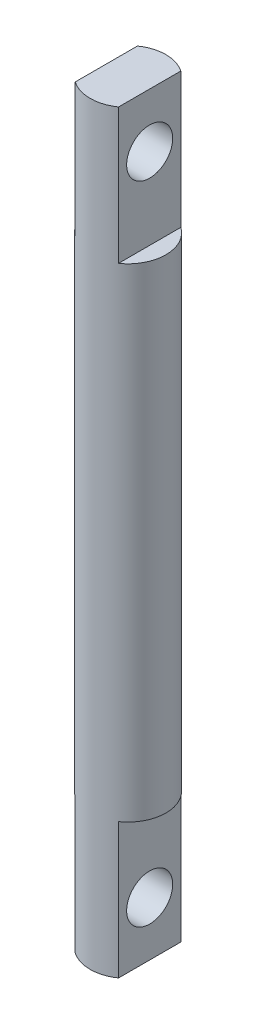
from build123d import *

# Parameters (mm, degrees)
SKETCH1_R                        = 7
BOSS_EXTRUDE1_DEPTH              = 139.254
SKETCH3_W                        = 3.842840079
SKETCH3_H                        = 19.362001934
SKETCH3_W_2                      = 3.621137766
CUT_EXTRUDE1_DEPTH               = 25
SKETCH4_W                        = 4.298001377
SKETCH4_H                        = 18.624672635
SKETCH4_W_2                      = 5.056472209
SKETCH4_H_2                      = 19.003908051
CUT_EXTRUDE2_DEPTH               = 25
TAP_DRILL_FOR_M10X1_5_TAP1_D     = 8.5
TAP_DRILL_FOR_M10X1_5_TAP1_DEPTH = 20
TAP_DRILL_FOR_M10X1_5_TAP1_TIP   = 2.553657631


with BuildPart() as part:
    # Sketch1 → Boss-Extrude1 (new body)
    with BuildSketch(Plane(origin=(0, 0, 0), x_dir=(1, 0, 0), z_dir=(0, 1, 0))):
        Circle(SKETCH1_R)
    extrude(amount=BOSS_EXTRUDE1_DEPTH)

    # Sketch3 → Cut-Extrude1 (cut)
    with BuildSketch(Plane.XZ):
        with Locations((5.92142004, -0.588495195)):
            Rectangle(SKETCH3_W, SKETCH3_H)
        with Locations((-5.810568883, -0.588495195)):
            Rectangle(SKETCH3_W_2, SKETCH3_H)
    extrude(amount=-CUT_EXTRUDE1_DEPTH, mode=Mode.SUBTRACT)

    # Sketch4 → Cut-Extrude2 (cut)
    with BuildSketch(Plane(origin=(0, 139.254, 0), x_dir=(1, 0, 0), z_dir=(0, 1, 0))):
        with Locations((-6.149000689, -0.400304049)):
            Rectangle(SKETCH4_W, SKETCH4_H)
        with Locations((6.528236105, -0.589921757)):
            Rectangle(SKETCH4_W_2, SKETCH4_H_2)
    extrude(amount=-CUT_EXTRUDE2_DEPTH, mode=Mode.SUBTRACT)

    # Tap Drill for M10x1.5 Tap1
    with Locations(Plane(origin=(4, 0, 0), x_dir=(0, 0, -1), z_dir=(1, 0, 0))):
        with Locations((0, 129.254), (0, 10)):
            Hole(TAP_DRILL_FOR_M10X1_5_TAP1_D / 2, depth=TAP_DRILL_FOR_M10X1_5_TAP1_DEPTH)
            with Locations((0, 0, -(TAP_DRILL_FOR_M10X1_5_TAP1_DEPTH + TAP_DRILL_FOR_M10X1_5_TAP1_TIP / 2))):  # 118° drill point
                Cone(0, TAP_DRILL_FOR_M10X1_5_TAP1_D / 2, TAP_DRILL_FOR_M10X1_5_TAP1_TIP, mode=Mode.SUBTRACT)


solid = part.part
